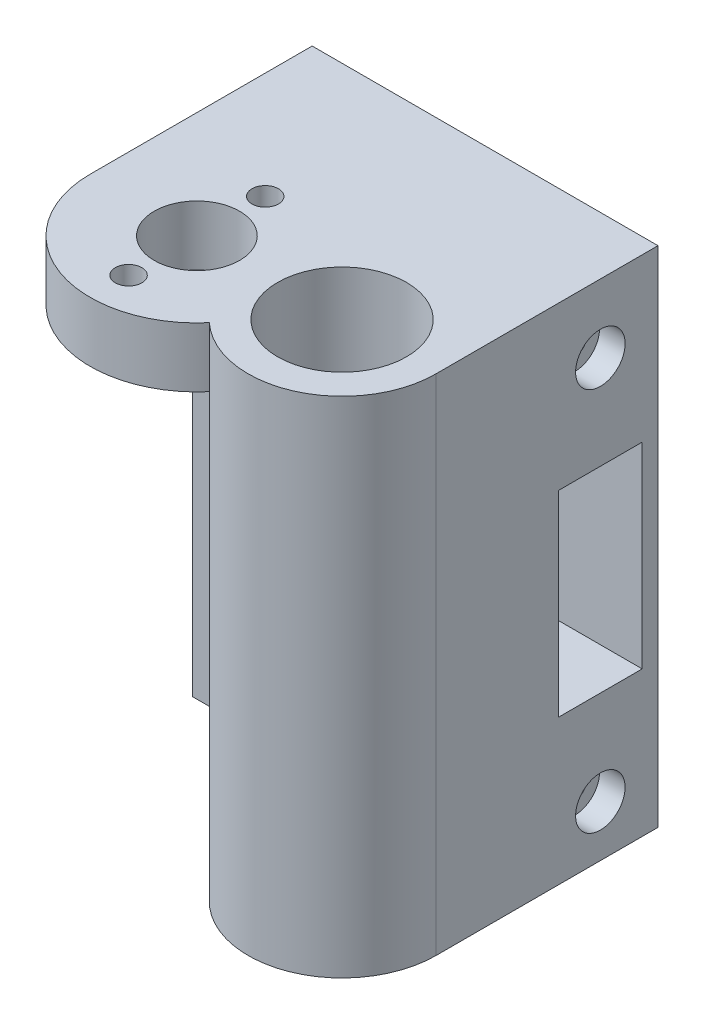
from build123d import *

# Parameters (mm, degrees)
CROQUIS1_R              = 5
CROQUIS1_R_2            = 7.55
SALIENTE_EXTRUIR1_DEPTH = 7
CROQUIS4_R              = 7.55
SALIENTE_EXTRUIR4_DEPTH = 52
CROQUIS5_R              = 4.1
CORTAR_EXTRUIR1_DEPTH   = 35
CROQUIS6_W              = 9.8
CROQUIS6_H              = 23
CORTAR_EXTRUIR2_DEPTH   = 41.5
CROQUIS7_R              = 1.4
CORTAR_EXTRUIR3_DEPTH   = 41.5
CROQUIS8_R              = 2.9
CROQUIS8_R_2            = 1.4
CORTAR_EXTRUIR4_DEPTH   = 3
CROQUIS10_R             = 1.5
CORTAR_EXTRUIR5_DEPTH   = 15
CROQUIS11_R             = 1.55
CORTAR_EXTRUIR6_DEPTH   = 60


with BuildPart() as part:
    # Croquis1 → Saliente-Extruir1 (new body)
    with BuildSketch(Plane(origin=(0, 0, 0), x_dir=(1, 0, 0), z_dir=(0, 1, 0))):
        with BuildLine():
            Line((28, 0), (28, 26))
            Line((28, 26), (-12.5, 26))
            Line((-12.5, 26), (-12.5, 0))
            ThreePointArc((-12.5, 0), (-4.303512587, -11.735833137), (9.536764706, -8.0808489))
            ThreePointArc((9.536764706, -8.0808489), (21.410465495, -10.077092543), (28, 0))
        make_face()
        Circle(CROQUIS1_R, mode=Mode.SUBTRACT)
        with Locations((17, 0)):
            Circle(CROQUIS1_R_2, mode=Mode.SUBTRACT)
    extrude(amount=SALIENTE_EXTRUIR1_DEPTH)

    # Croquis4 → Saliente-Extruir4 (add)
    with BuildSketch(Plane.XZ):
        with BuildLine():
            Line((-12.5, -12), (-12.5, -26))
            Line((-12.5, -26), (28, -26))
            Line((28, -26), (28, 0))
            ThreePointArc((28, 0), (21.410465495, 10.077092543), (9.536764706, 8.0808489))
            ThreePointArc((9.536764706, 8.0808489), (6.922907457, 4.410465495), (6, 0))
            Line((6, 0), (6, -12))
            Line((6, -12), (-12.5, -12))
        make_face()
        with Locations((17, 0)):
            Circle(CROQUIS4_R, mode=Mode.SUBTRACT)
    extrude(amount=SALIENTE_EXTRUIR4_DEPTH)

    # Croquis5 → Cortar-Extruir1 (cut)
    with BuildSketch(Plane.ZY.offset(12.5)):
        with Locations((-19.25, -1)):
            Circle(CROQUIS5_R)
        with Locations((-19.25, -46)):
            Circle(CROQUIS5_R)
    extrude(amount=-CORTAR_EXTRUIR1_DEPTH, mode=Mode.SUBTRACT)

    # Croquis6 → Cortar-Extruir2 (cut, through all)
    with BuildSketch(Plane.ZY.offset(12.5)):
        with Locations((-19.25, -23.5)):
            Rectangle(CROQUIS6_W, CROQUIS6_H)
    extrude(amount=-CORTAR_EXTRUIR2_DEPTH, mode=Mode.SUBTRACT)

    # Croquis7 → Cortar-Extruir3 (cut, through all)
    with BuildSketch(Plane(origin=(28, 0, 0), x_dir=(0, 0, -1), z_dir=(1, 0, 0))):
        with Locations((19.25, -1)):
            Circle(CROQUIS7_R)
        with Locations((19.25, -46)):
            Circle(CROQUIS7_R)
    extrude(amount=-CORTAR_EXTRUIR3_DEPTH, mode=Mode.SUBTRACT)

    # Croquis8 → Cortar-Extruir4 (cut)
    with BuildSketch(Plane(origin=(28, 0, 0), x_dir=(0, 0, -1), z_dir=(1, 0, 0))):
        with Locations((19.25, -1)):
            Circle(CROQUIS8_R)
        with Locations((19.25, -1)):
            Circle(CROQUIS8_R_2, mode=Mode.SUBTRACT)
        with Locations((19.25, -46)):
            Circle(CROQUIS8_R)
        with Locations((19.25, -46)):
            Circle(CROQUIS8_R_2, mode=Mode.SUBTRACT)
    extrude(amount=-CORTAR_EXTRUIR4_DEPTH, mode=Mode.SUBTRACT)

    # Croquis10 → Cortar-Extruir5 (cut, through all)
    with BuildSketch(Plane.XY.offset(-12)):
        with Locations((-5.5, -23.5)):
            Circle(CROQUIS10_R)
    extrude(amount=-CORTAR_EXTRUIR5_DEPTH, mode=Mode.SUBTRACT)

    # Croquis11 → Cortar-Extruir6 (cut, through all)
    with BuildSketch(Plane(origin=(0, 7, 0), x_dir=(1, 0, 0), z_dir=(0, 1, 0))):
        with Locations((0, 8)):
            Circle(CROQUIS11_R)
        with Locations((0, -8)):
            Circle(CROQUIS11_R)
    extrude(amount=-CORTAR_EXTRUIR6_DEPTH, mode=Mode.SUBTRACT)


solid = part.part
